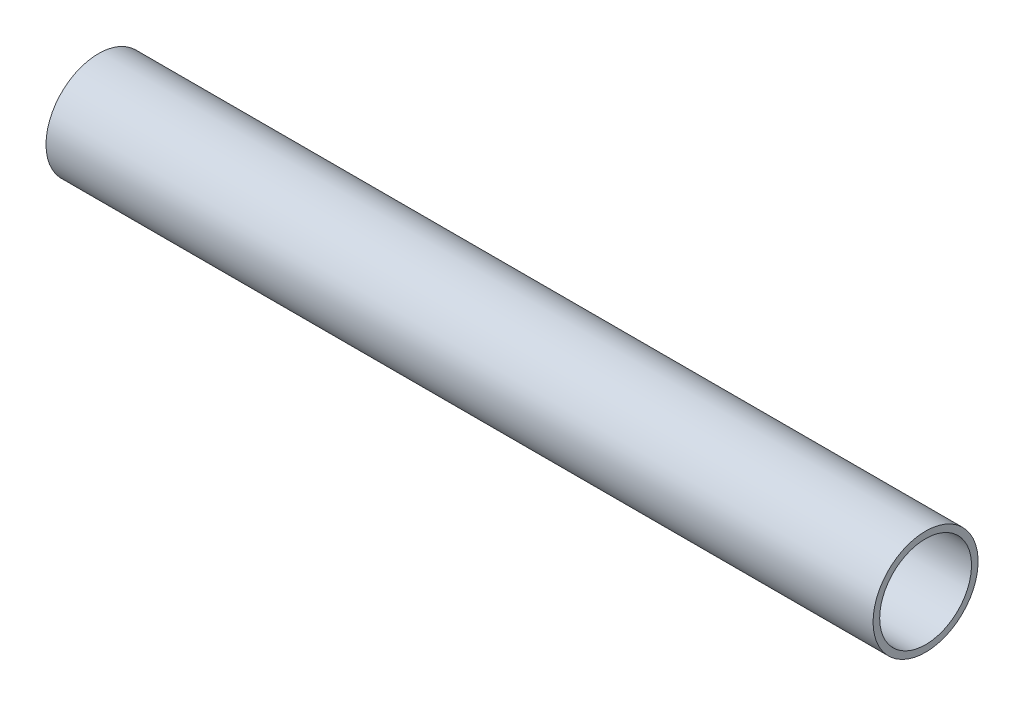
from build123d import *

# Parameters (mm, degrees)
ESBO_O1_W = 600
ESBO_O1_H = 4.8


with BuildPart() as part:
    # Esboço1 → Revolução1 (revolve)
    with BuildSketch(Plane.XY):
        with Locations((300, 35.7)):
            Rectangle(ESBO_O1_W, ESBO_O1_H)
    revolve(axis=Axis((0, 0, 0), (1, 0, 0)))


solid = part.part
